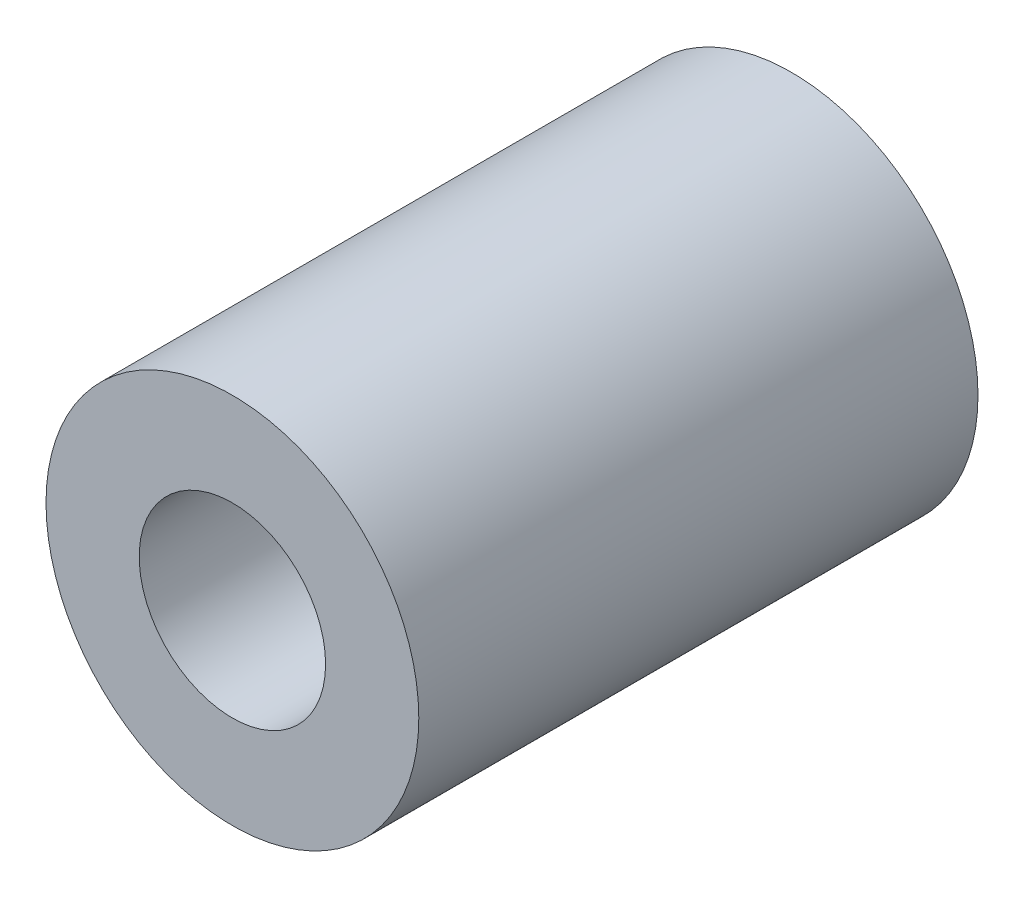
from build123d import *

# Parameters (mm, degrees)
CROQUIS1_R              = 3
CROQUIS1_R_2            = 1.5
SALIENTE_EXTRUIR1_DEPTH = 9


with BuildPart() as part:
    # Croquis1 → Saliente-Extruir1 (new body)
    with BuildSketch(Plane.XY):
        Circle(CROQUIS1_R)
        Circle(CROQUIS1_R_2, mode=Mode.SUBTRACT)
    extrude(amount=SALIENTE_EXTRUIR1_DEPTH)


solid = part.part
